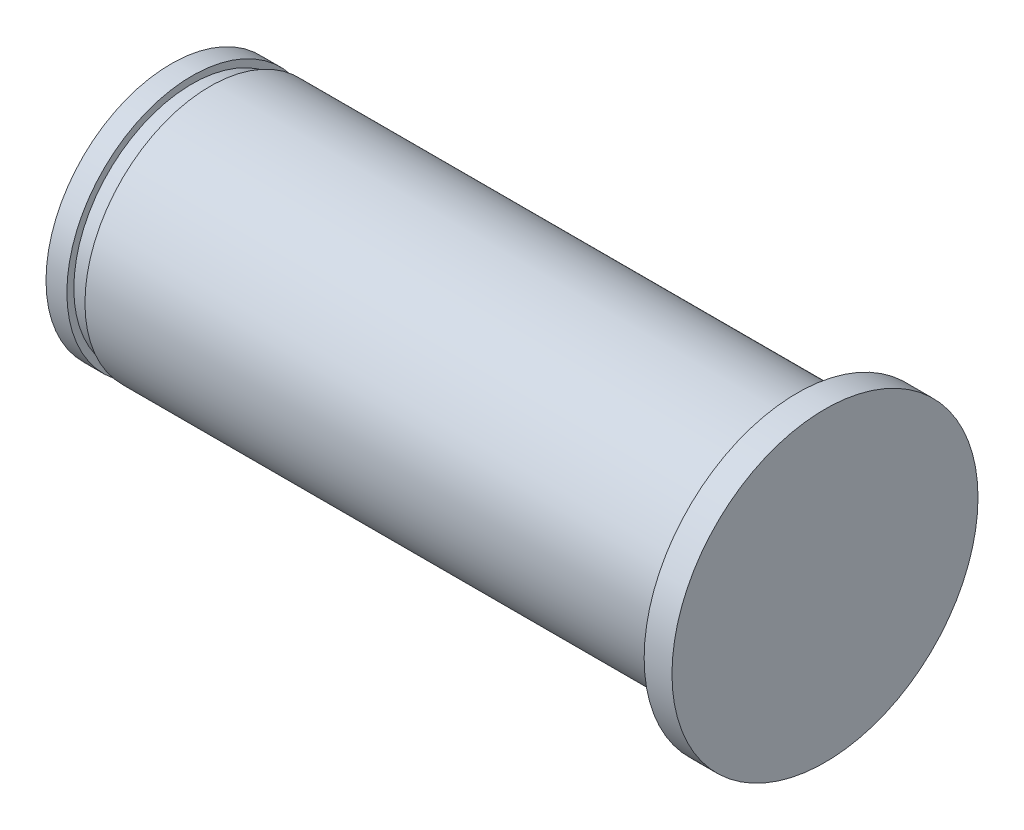
from build123d import *


with BuildPart() as part:
    # Skica1 → Rotovat1 (revolve)
    with BuildSketch(Plane.XY):
        Polygon((0, 0), (0, 9), (1.5, 9), (1.5, 8.5), (2.8, 8.5), (2.8, 9), (45, 9), (45, 11), (47, 11), (47, 0), align=None)
    revolve(axis=Axis((-20.403120127, 0, 0), (1, 0, 0)))


solid = part.part
